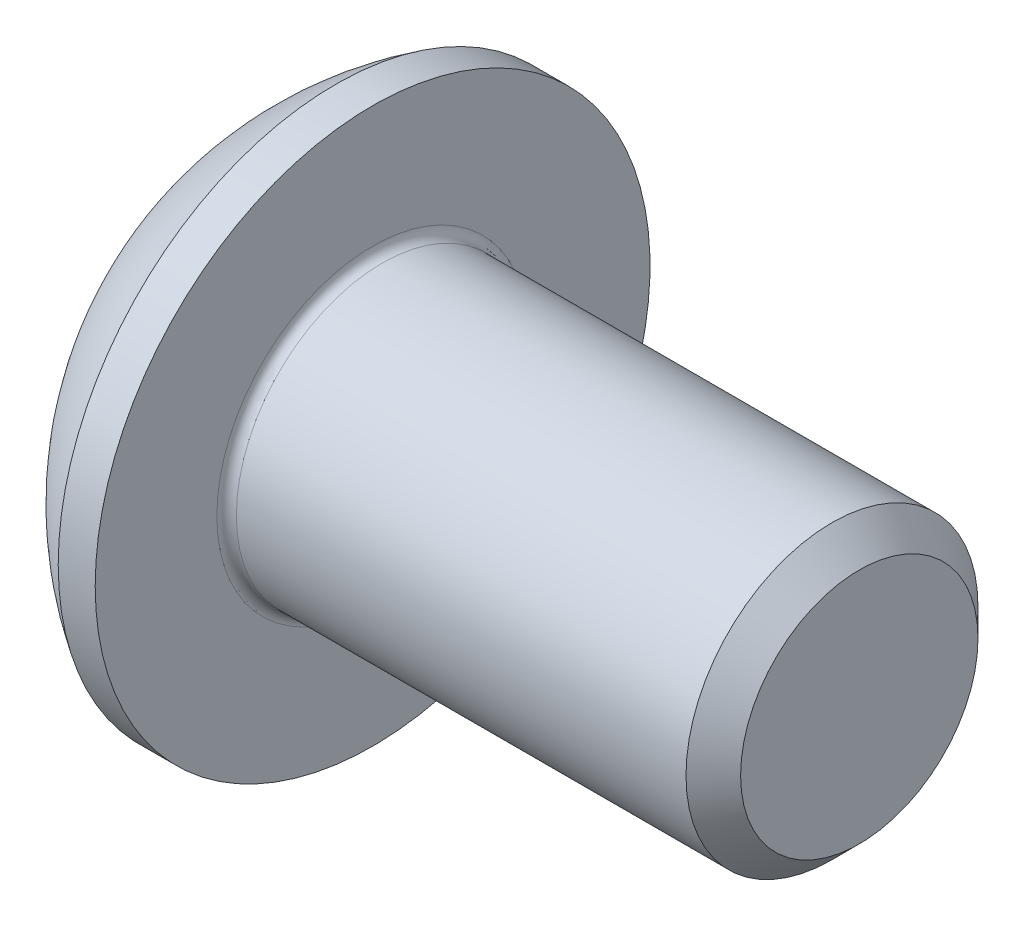
from build123d import *

# Parameters (mm, degrees)
FILLET1_R   = 0.1
HEX_2_DEPTH = 1.04


with BuildPart() as part:
    # BodySke → BaseBody (revolve)
    with BuildSketch(Plane.XY):
        with BuildLine():
            Line((6.65, 0), (6.65, 1.2195))
            Line((6.65, 1.2195), (6.3695, 1.5))
            Line((6.3695, 1.5), (1.65, 1.5))
            Line((1.65, 1.5), (1.65, 2.85))
            Line((1.65, 2.85), (1.27, 2.85))
            ThreePointArc((1.27, 2.85), (0.53140404, 2.229827628), (0, 1.425))
            Line((0, 1.425), (0, 0))
            Line((0, 0), (6.65, 0))
        make_face()
    revolve(axis=Axis((0, 0, 0), (1, 0, 0)))

    # Fillet1
    fillet1_edges = [part.edges().sort_by_distance(p)[0] for p in [
        (1.65, -1.5, 0),
    ]]
    fillet(fillet1_edges, radius=FILLET1_R)

    # Sketch2 → PreBroach (revolve, cut)
    with BuildSketch(Plane.XY):
        Polygon((0, 1), (1.04, 1), (1.617350269, 0), (0, 0), align=None)
    revolve(axis=Axis((0, 0, 0), (1, 0, 0)), mode=Mode.SUBTRACT)

    # Sketch3 → Hex 2 (cut)
    with BuildSketch(Plane(origin=(0, 0, 0), x_dir=(0, 0, -1), z_dir=(1, 0, 0))):
        Polygon((-1, -0.577350269), (-1, 0.577350269), (0, 1.154700538), (1, 0.577350269), (1, -0.577350269), (0, -1.154700538), align=None)
    extrude(amount=HEX_2_DEPTH, mode=Mode.SUBTRACT)


solid = part.part
